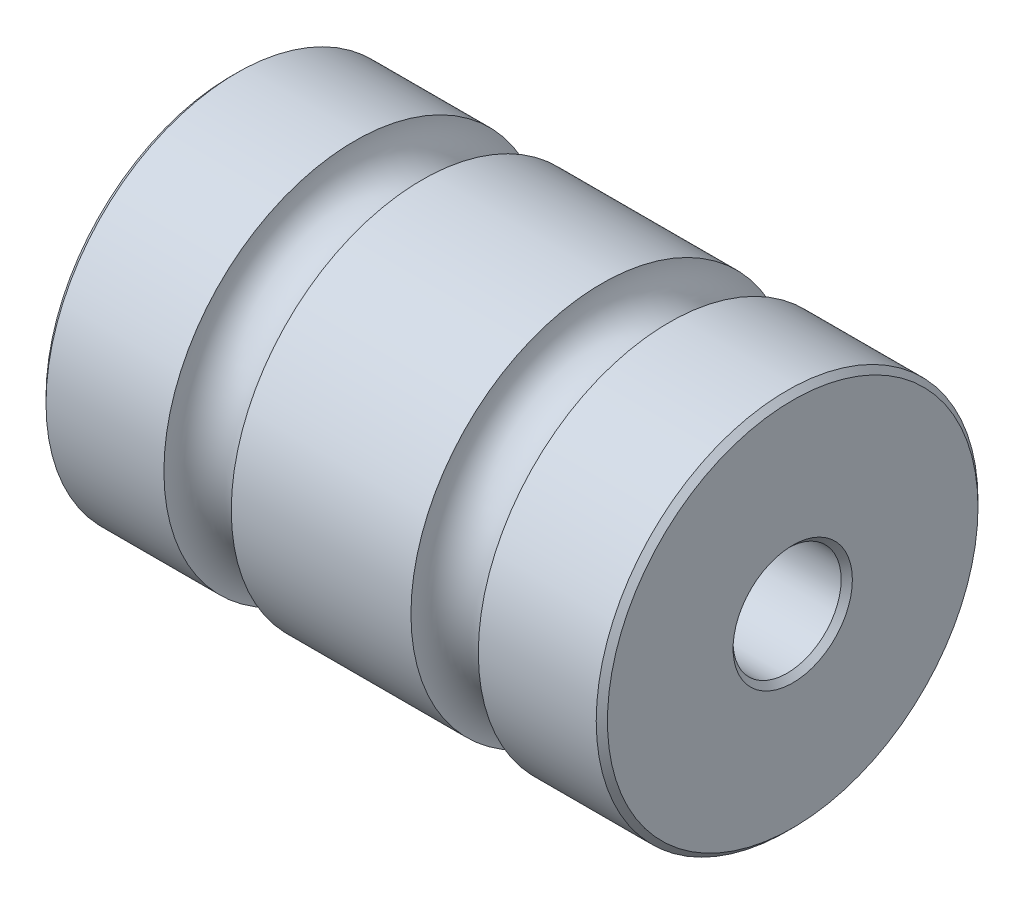
from build123d import *

# Parameters (mm, degrees)
SKETCH3_R          = 4.8125
CUT_EXTRUDE2_DEPTH = 51
CHAMFER1_SIZE      = 0.5


with BuildPart() as part:
    # Sketch1 → Revolve1 (revolve)
    with BuildSketch(Plane.XY):
        with BuildLine():
            Line((-25, 0), (25, 0))
            Line((25, 0), (25, -17))
            Line((25, -17), (14, -17))
            ThreePointArc((14, -17), (11, -14), (8, -17))
            Line((8, -17), (-8, -17))
            ThreePointArc((-8, -17), (-11, -14), (-14, -17))
            Line((-14, -17), (-25, -17))
            Line((-25, -17), (-25, 0))
        make_face()
    revolve(axis=Axis((-25, 0, 0), (1, 0, 0)))

    # Sketch3 → Cut-Extrude2 (cut, through all)
    with BuildSketch(Plane(origin=(25, 0, 0), x_dir=(0, 0, -1), z_dir=(1, 0, 0))):
        Circle(SKETCH3_R)
    extrude(amount=-CUT_EXTRUDE2_DEPTH, mode=Mode.SUBTRACT)

    # Chamfer1
    chamfer1_edges = [part.edges().sort_by_distance(p)[0] for p in [
        (25, 17, 0),
        (-25, 0, 4.8125),
        (25, 0, 4.8125),
        (-25, 17, 0),
    ]]
    chamfer(chamfer1_edges, length=CHAMFER1_SIZE)


solid = part.part
